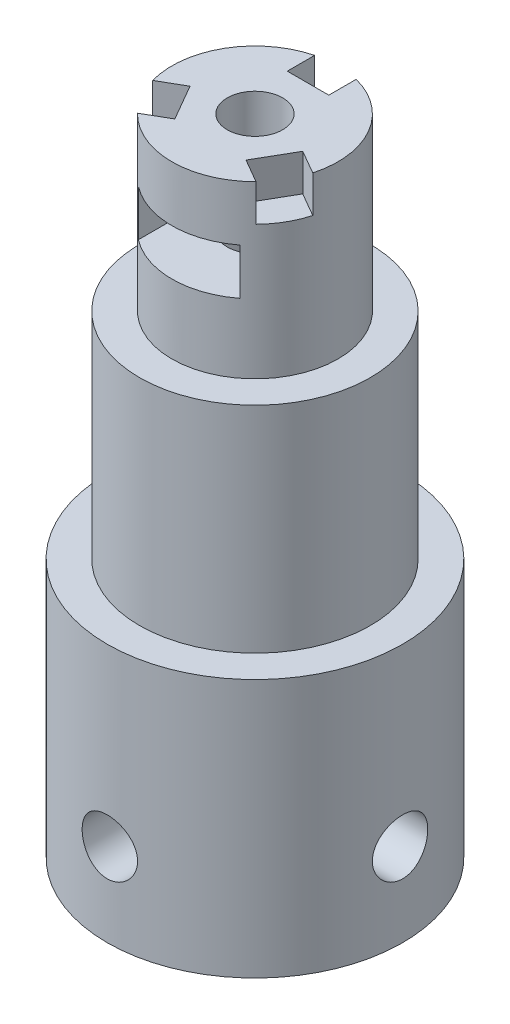
from build123d import *

# Parameters (mm, degrees)
SKETCH1_R           = 8
SKETCH1_R_2         = 3.125
BOSS_EXTRUDE1_DEPTH = 14
SKETCH2_R           = 1.5
CUT_EXTRUDE1_DEPTH  = 9
CUT_EXTRUDE2_START  = -3.025
CUT_EXTRUDE2_DEPTH  = 2.25
CUT_EXTRUDE3_START  = 3.025
CUT_EXTRUDE3_DEPTH  = 2.25
SKETCH5_R           = 6.25
BOSS_EXTRUDE2_DEPTH = 11.63
SKETCH6_R           = 4.5
BOSS_EXTRUDE3_DEPTH = 9.25
SKETCH7_R           = 1.5
CUT_EXTRUDE4_DEPTH  = 8
CUT_EXTRUDE5_START  = -3
SKETCH8_R           = 1.5
CUT_EXTRUDE5_DEPTH  = 2.5
SKETCH9_W           = 2.25
SKETCH9_H           = 3.25
CUT_EXTRUDE6_DEPTH  = 2
CIRPATTERN1_COUNT   = 3
CIRPATTERN3_COUNT   = 2
CIRPATTERN3_ANGLE   = 90


with BuildPart() as part:
    # Sketch1 → Boss-Extrude1 (new body)
    with BuildSketch(Plane(origin=(0, 0, 0), x_dir=(1, 0, 0), z_dir=(0, 1, 0))):
        Circle(SKETCH1_R)
        Circle(SKETCH1_R_2, mode=Mode.SUBTRACT)
    extrude(amount=BOSS_EXTRUDE1_DEPTH)

    # Sketch2 → Cut-Extrude1 (cut, symmetric)
    with BuildSketch(Plane.XY):
        with Locations((0, 4.5)):
            Circle(SKETCH2_R)
    cut_extrude1 = extrude(amount=CUT_EXTRUDE1_DEPTH, both=True, mode=Mode.SUBTRACT)

    # Sketch3 → Cut-Extrude2 (cut)
    with BuildSketch(Plane.XY.offset(CUT_EXTRUDE2_START)):
        Polygon((-2.75, 2.91228676), (0, 1.324573519), (2.75, 2.91228676), (2.75, 0), (-2.75, 0), align=None)
        Polygon((2.75, 2.91228676), (-2.75, 2.91228676), (-2.75, 6.08771324), (0, 7.675426481), (2.75, 6.08771324), align=None)
        Polygon((0, 1.324573519), (2.75, 2.91228676), (-2.75, 2.91228676), align=None)
    extrude(amount=-CUT_EXTRUDE2_DEPTH, mode=Mode.SUBTRACT)

    # Sketch4 → Cut-Extrude3 (cut)
    with BuildSketch(Plane.XY.offset(CUT_EXTRUDE3_START)):
        Polygon((-2.75, 2.91228676), (0, 1.324573519), (2.75, 2.91228676), (2.75, 0), (-2.75, 0), align=None)
        Polygon((0, 1.324573519), (2.75, 2.91228676), (-2.75, 2.91228676), align=None)
        Polygon((2.75, 2.91228676), (-2.75, 2.91228676), (-2.75, 6.08771324), (0, 7.675426481), (2.75, 6.08771324), align=None)
    extrude(amount=CUT_EXTRUDE3_DEPTH, mode=Mode.SUBTRACT)

    # Sketch5 → Boss-Extrude2 (add)
    with BuildSketch(Plane(origin=(0, 14, 0), x_dir=(1, 0, 0), z_dir=(0, 1, 0))):
        Circle(SKETCH5_R)
    extrude(amount=BOSS_EXTRUDE2_DEPTH)

    # Sketch6 → Boss-Extrude3 (add)
    with BuildSketch(Plane(origin=(0, 25.63, 0), x_dir=(1, 0, 0), z_dir=(0, 1, 0))):
        Circle(SKETCH6_R)
    extrude(amount=BOSS_EXTRUDE3_DEPTH)

    # Sketch7 → Cut-Extrude4 (cut)
    with BuildSketch(Plane(origin=(0, 34.88, 0), x_dir=(1, 0, 0), z_dir=(0, 1, 0))):
        Circle(SKETCH7_R)
    extrude(amount=-CUT_EXTRUDE4_DEPTH, mode=Mode.SUBTRACT)

    # Sketch8 → Cut-Extrude5 (cut)
    with BuildSketch(Plane(origin=(0, 34.88, 0), x_dir=(1, 0, 0), z_dir=(0, 1, 0)).offset(CUT_EXTRUDE5_START)):
        with BuildLine():
            Line((2.75, -1.58771324), (0, -3.175426481))
            Line((0, -3.175426481), (-2.75, -1.58771324))
            Line((-2.75, -1.58771324), (-2.75, -3.561951712))
            ThreePointArc((-2.75, -3.561951712), (0, -4.5), (2.75, -3.561951712))
            Line((2.75, -3.561951712), (2.75, -1.58771324))
        make_face()
        Polygon((-2.75, -1.58771324), (2.75, -1.58771324), (0, -3.175426481), align=None)
        Polygon((-2.75, 1.58771324), (-2.75, -1.58771324), (2.75, -1.58771324), (2.75, 1.58771324), (0, 3.175426481), align=None)
        Circle(SKETCH8_R, mode=Mode.SUBTRACT)
    extrude(amount=-CUT_EXTRUDE5_DEPTH, mode=Mode.SUBTRACT)

    # Sketch9 → Cut-Extrude6 (cut)
    with BuildSketch(Plane(origin=(0, 34.88, 0), x_dir=(1, 0, 0), z_dir=(0, 1, 0))):
        with Locations((0, 4.5)):
            Rectangle(SKETCH9_W, SKETCH9_H)
    cut_extrude6 = extrude(amount=-CUT_EXTRUDE6_DEPTH, mode=Mode.SUBTRACT)

    # CirPattern1: Cut-Extrude6 ×3 about axis
    cirpattern1_axis = Axis((0, 0, 0), (0, 1, 0))
    for i in range(1, CIRPATTERN1_COUNT):
        add(cut_extrude6.rotate(cirpattern1_axis, i * 360 / CIRPATTERN1_COUNT), mode=Mode.SUBTRACT)

    # CirPattern3: Cut-Extrude1 ×2 about axis
    cirpattern3_axis = Axis((0, 0, 0), (0, 1, 0))
    for i in range(1, CIRPATTERN3_COUNT):
        add(cut_extrude1.rotate(cirpattern3_axis, i * CIRPATTERN3_ANGLE / (CIRPATTERN3_COUNT - 1)), mode=Mode.SUBTRACT)


solid = part.part
